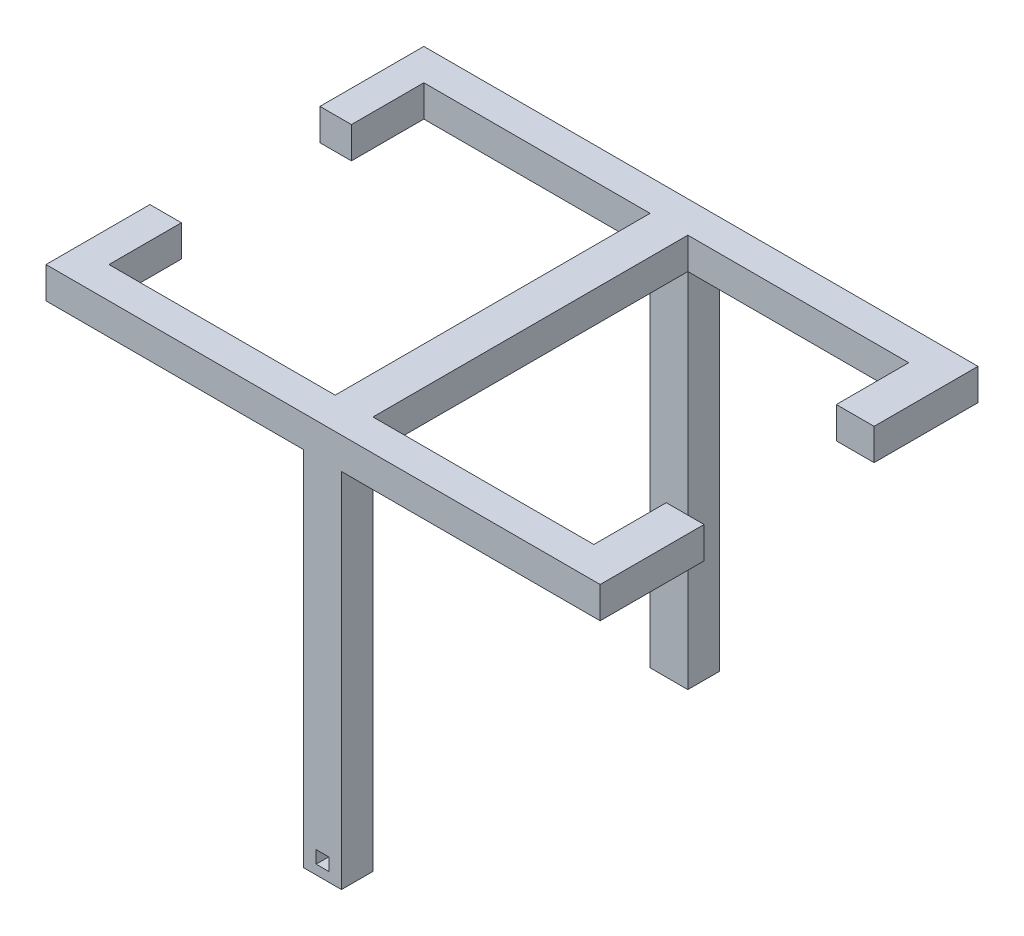
from build123d import *

# Parameters (mm, degrees)
SKETCH1_W           = 176
SKETCH1_H           = 10
BOSS_EXTRUDE1_DEPTH = 10
SKETCH2_W           = 12
SKETCH2_H           = 10
BOSS_EXTRUDE2_DEPTH = 50
SKETCH3_W           = 10
SKETCH3_H           = 10
SKETCH3_W_2         = 12
BOSS_EXTRUDE3_DEPTH = 23
SKETCH4_W           = 12
SKETCH4_H           = 10
BOSS_EXTRUDE4_DEPTH = 115
SKETCH6_W           = 4
SKETCH6_H           = 4
CUT_EXTRUDE1_DEPTH  = 5
SKETCH7_W           = 4
SKETCH7_H           = 4
CUT_EXTRUDE2_DEPTH  = 5


with BuildPart() as part:
    # Sketch1 → Boss-Extrude1 (new body)
    with BuildSketch(Plane.XY):
        with Locations((88, 5)):
            Rectangle(SKETCH1_W, SKETCH1_H)
    extrude(amount=BOSS_EXTRUDE1_DEPTH)

    # Sketch2 → Boss-Extrude2 (add)
    with BuildSketch(Plane(origin=(0, 0, 0), x_dir=(-1, 0, 0), z_dir=(0, 0, -1))):
        with Locations((-87.845258849, 5)):
            Rectangle(SKETCH2_W, SKETCH2_H)
    extrude(amount=BOSS_EXTRUDE2_DEPTH)

    # Sketch3 → Boss-Extrude3 (add)
    with BuildSketch(Plane(origin=(0, 0, 0), x_dir=(-1, 0, 0), z_dir=(0, 0, -1))):
        with Locations((-5, 5)):
            Rectangle(SKETCH3_W, SKETCH3_H)
        with Locations((-170, 5)):
            Rectangle(SKETCH3_W_2, SKETCH3_H)
    extrude(amount=BOSS_EXTRUDE3_DEPTH)

    # Mirror6: part across plane


with BuildPart() as part_1:
    add(part.part)
    add(part.part.mirror(Plane.XY.offset(-50)))

    # Sketch4 → Boss-Extrude4 (add)
    with BuildSketch(Plane.XZ):
        with Locations((87.845258849, 5)):
            Rectangle(SKETCH4_W, SKETCH4_H)
        with Locations((87.845258849, -105)):
            Rectangle(SKETCH4_W, SKETCH4_H)
    extrude(amount=BOSS_EXTRUDE4_DEPTH)

    # Sketch6 → Cut-Extrude1 (cut)
    with BuildSketch(Plane.XY.offset(10)):
        with Locations((87.80305242, -110.022825142)):
            Rectangle(SKETCH6_W, SKETCH6_H)
    extrude(amount=-CUT_EXTRUDE1_DEPTH, mode=Mode.SUBTRACT)

    # Sketch7 → Cut-Extrude2 (cut)
    with BuildSketch(Plane(origin=(0, 0, -110), x_dir=(-1, 0, 0), z_dir=(0, 0, -1))):
        with Locations((-87.845258849, -110)):
            Rectangle(SKETCH7_W, SKETCH7_H)
    extrude(amount=-CUT_EXTRUDE2_DEPTH, mode=Mode.SUBTRACT)


solid = part_1.part
